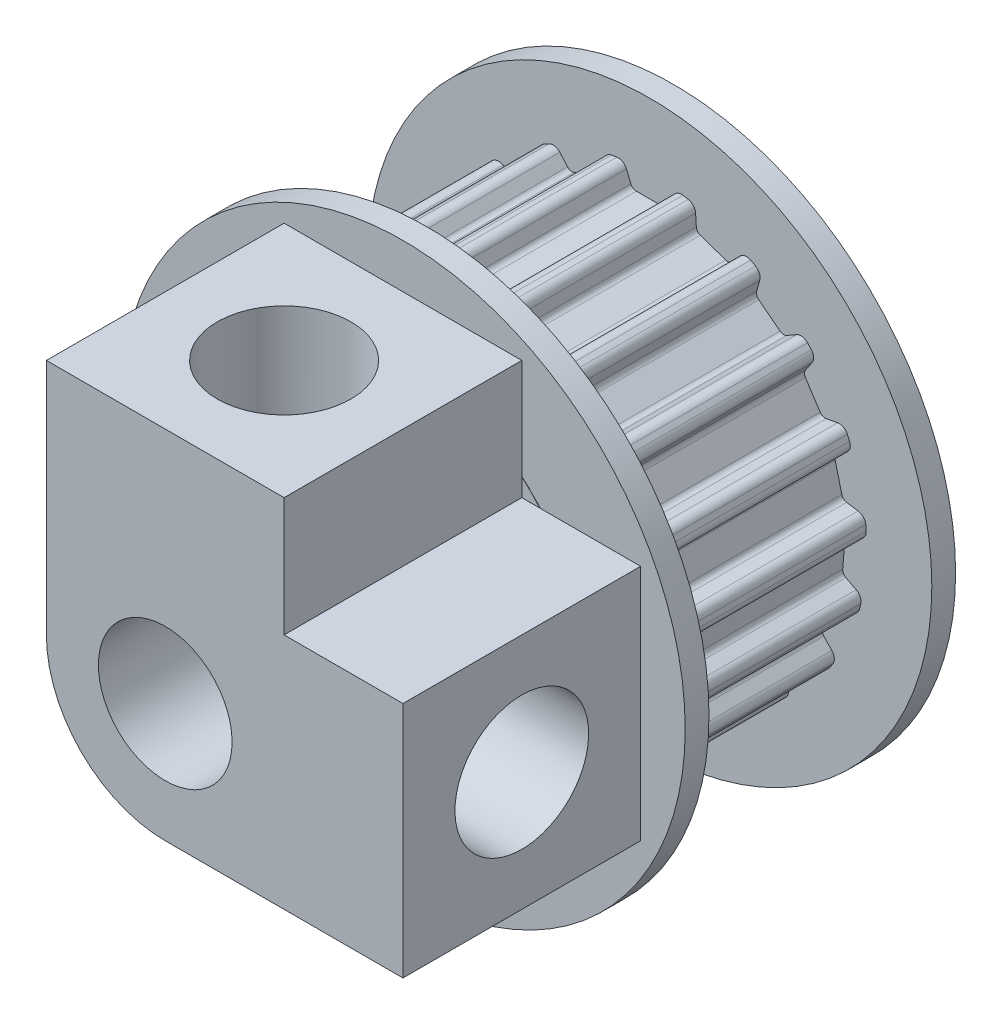
from build123d import *

# Parameters (mm, degrees)
TOOTH_EXTRUDE_START    = -3.75
TOOTH_EXTRUDE_DEPTH    = 7.5
TOOTH_PATTERN_19_COUNT = 19
SKETCH3_R              = 2.25
CUT_EXTRUDE2_DEPTH     = 10.12
SKETCH6_R              = 2.25
BOSS_EXTRUDE1_DEPTH    = 8
SKETCH7_R              = 2.25
CUT_EXTRUDE3_DEPTH     = 8
SKETCH8_R              = 2.25
CUT_EXTRUDE4_DEPTH     = 8


with BuildPart() as part:
    # GearBelt-BaseSketch → T 2_5 Form SE DIN 7721_ 6mm Belt Width (revolve)
    with BuildSketch(Plane(origin=(0, 0, 0), x_dir=(0, 0, -1), z_dir=(1, 0, 0))):
        Polygon((-4.56, 0), (4.56, 0), (4.56, 6.099999905), (4.55, 6.099999905), (4.55, 7.330870102), (4.55, 9.49), (3.75, 9.49), (3.75, 7.49), (3.75, 7.3), (-3.75, 7.3), (-3.75, 7.49), (-3.75, 9.49), (-4.55, 9.49), (-4.55, 7.330870102), (-4.55, 6.099999905), (-4.56, 6.099999905), align=None)
    revolve(axis=Axis((0, 0, 6.84), (0, 0, -1)))

    # Tooth-Sketch → Tooth-Extrude (cut)
    with BuildSketch(Plane.XY.offset(TOOTH_EXTRUDE_START)):
        with BuildLine():
            Line((-0.453445584, 6.55), (0.453445584, 6.55))
            ThreePointArc((0.453445584, 6.55), (0.564559632, 6.583706078), (0.638221493, 6.673463315))
            Line((0.638221493, 6.673463315), (0.787310301, 7.033395539))
            ThreePointArc((0.787310301, 7.033395539), (0.917309737, 7.18001475), (1.110094497, 7.215101538))
            Line((1.110094497, 7.215101538), (1.110094497, 9.755101538))
            Line((1.110094497, 9.755101538), (-1.110094497, 9.755101538))
            Line((-1.110094497, 9.755101538), (-1.110094497, 7.215101538))
            ThreePointArc((-1.110094497, 7.215101538), (-0.917309737, 7.18001475), (-0.787310301, 7.033395539))
            Line((-0.787310301, 7.033395539), (-0.638221493, 6.673463315))
            ThreePointArc((-0.638221493, 6.673463315), (-0.564559632, 6.583706078), (-0.453445584, 6.55))
        make_face()
    tooth_extrude = extrude(amount=TOOTH_EXTRUDE_DEPTH, mode=Mode.SUBTRACT)

    # Tooth Pattern_ 19: Tooth-Extrude ×19 about axis
    tooth_pattern_19_axis = Axis((0, 0, 0), (0, 0, 1))
    for i in range(1, TOOTH_PATTERN_19_COUNT):
        add(tooth_extrude.rotate(tooth_pattern_19_axis, i * 360 / TOOTH_PATTERN_19_COUNT), mode=Mode.SUBTRACT)

    # Sketch3 → Cut-Extrude2 (cut, through all)
    with BuildSketch(Plane.XY.offset(4.56)):
        Circle(SKETCH3_R)
    extrude(amount=-CUT_EXTRUDE2_DEPTH, mode=Mode.SUBTRACT)

    # Sketch6 → Boss-Extrude1 (add)
    with BuildSketch(Plane.XY.offset(4.56)):
        with BuildLine():
            Line((-4, 0), (-4, 8))
            Line((-4, 8), (4, 8))
            Line((4, 8), (4, 4))
            Line((4, 4), (8, 4))
            Line((8, 4), (8, -4))
            Line((8, -4), (0, -4))
            ThreePointArc((0, -4), (-2.828427125, -2.828427125), (-4, 0))
        make_face()
        Circle(SKETCH6_R, mode=Mode.SUBTRACT)
    extrude(amount=BOSS_EXTRUDE1_DEPTH)

    # Sketch7 → Cut-Extrude3 (cut)
    with BuildSketch(Plane(origin=(0, 8, 0), x_dir=(1, 0, 0), z_dir=(0, 1, 0))):
        with Locations((0, -8.56)):
            Circle(SKETCH7_R)
    extrude(amount=-CUT_EXTRUDE3_DEPTH, mode=Mode.SUBTRACT)

    # Sketch8 → Cut-Extrude4 (cut)
    with BuildSketch(Plane(origin=(8, 0, 0), x_dir=(0, 0, -1), z_dir=(1, 0, 0))):
        with Locations((-8.56, 0)):
            Circle(SKETCH8_R)
    extrude(amount=-CUT_EXTRUDE4_DEPTH, mode=Mode.SUBTRACT)


solid = part.part
